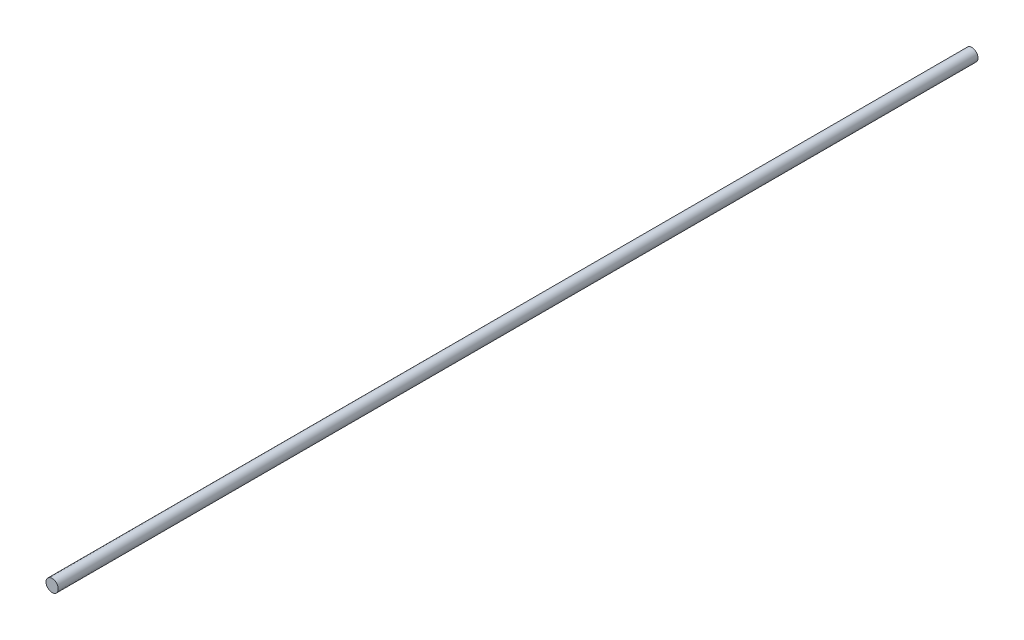
from build123d import *

# Parameters (mm, degrees)
SKETCH1_R           = 4
BOSS_EXTRUDE1_DEPTH = 600


with BuildPart() as part:
    # Sketch1 → Boss-Extrude1 (new body)
    with BuildSketch(Plane.XY):
        Circle(SKETCH1_R)
    extrude(amount=BOSS_EXTRUDE1_DEPTH)


solid = part.part
